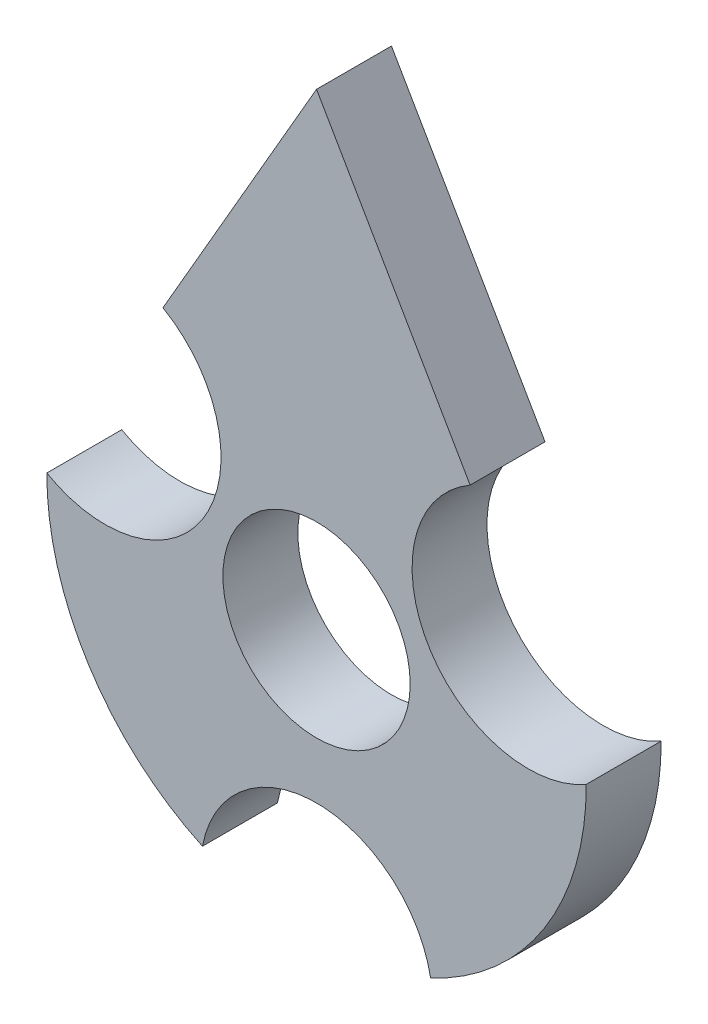
from build123d import *

# Parameters (mm, degrees)
SKETCH1_R           = 25
BOSS_EXTRUDE1_DEPTH = 10


with BuildPart() as part:
    # Sketch1 → Boss-Extrude1 (new body, symmetric)
    with BuildSketch(Plane.XY):
        with BuildLine():
            Line((41, 53.98591689), (0, 125))
            Line((0, 125), (-41, 53.98591689))
            ThreePointArc((-41, 53.98591689), (-29.653041557, 11.639425428), (-71.999407886, 0.292000007))
            ThreePointArc((-71.999407886, 0.292000007), (-60.81182851, -38.5476525), (-30.460070741, -65.23943662))
            ThreePointArc((-30.460070741, -65.23943662), (0, -40), (30.460070741, -65.23943662))
            ThreePointArc((30.460070741, -65.23943662), (60.81182851, -38.5476525), (71.999407886, 0.292000007))
            ThreePointArc((71.999407886, 0.292000007), (29.653041557, 11.639425428), (41, 53.98591689))
        make_face()
        Circle(SKETCH1_R, mode=Mode.SUBTRACT)
    extrude(amount=BOSS_EXTRUDE1_DEPTH, both=True)


solid = part.part
